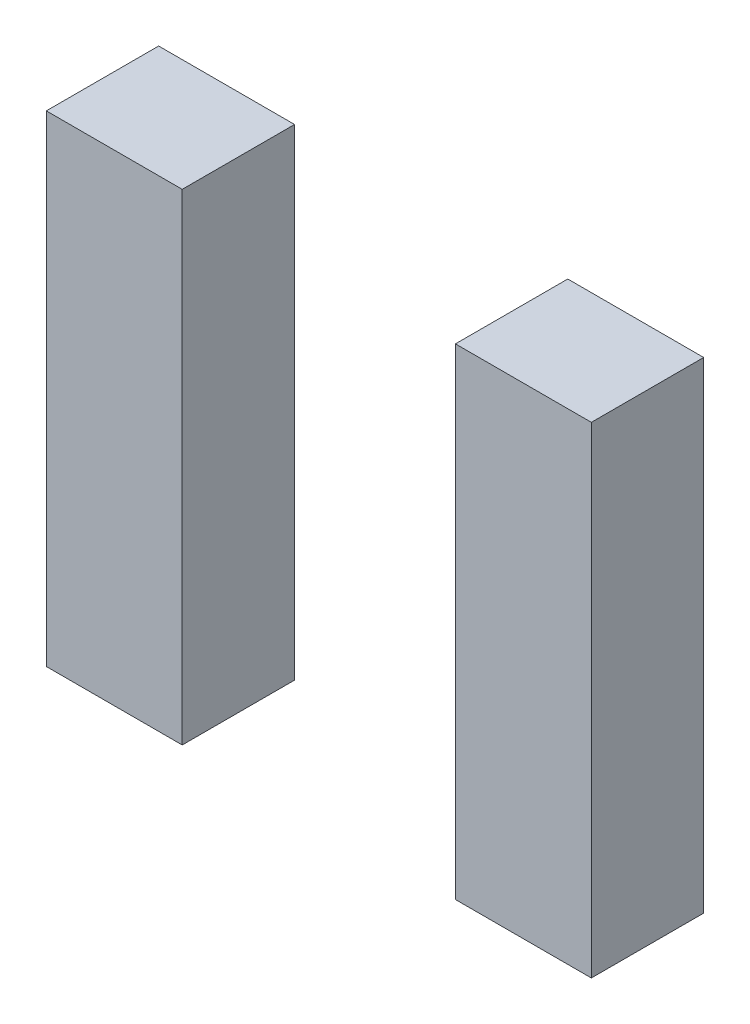
from build123d import *

# Parameters (mm, degrees)
SKETCH1_W             = 24.892
SKETCH1_H             = 88.138
BOSS_EXTRUDE1_DEPTH   = 20.574
BOSS_EXTRUDE1_2_DEPTH = 20.574


with BuildPart() as part:
    # Sketch1 → Boss-Extrude1 (new body)
    with BuildSketch(Plane.XY):
        with Locations((-20.2819, 0)):
            Rectangle(SKETCH1_W, SKETCH1_H)
    extrude(amount=BOSS_EXTRUDE1_DEPTH)


with BuildPart() as body_2:
    # Sketch1 → Boss-Extrude1 2 (new body)
    with BuildSketch(Plane.XY):
        with Locations((-95.2119, -0.508)):
            Rectangle(SKETCH1_W, SKETCH1_H)
    extrude(amount=BOSS_EXTRUDE1_2_DEPTH)


solid = Compound([part.part, body_2.part])
